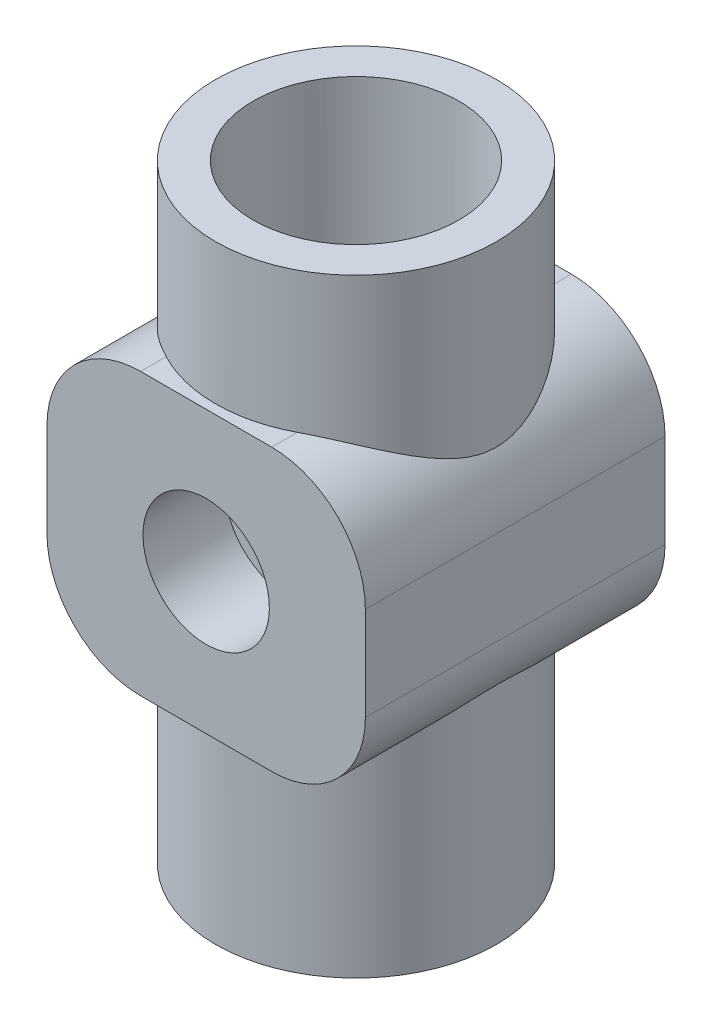
from build123d import *

# Parameters (mm, degrees)
BOSS_EXTRUDE1_DEPTH      = 16
SKETCH2_R                = 15
SKETCH2_R_2              = 11
BOSS_EXTRUDE2_DEPTH      = 30
BOSS_EXTRUDE2_DEPTH_BACK = 35
SKETCH3_R                = 6.75
CUT_EXTRUDE1_DEPTH       = 8.75
SKETCH4_R                = 11
CUT_EXTRUDE2_DEPTH       = 24


with BuildPart() as part:
    # Sketch1 → Boss-Extrude1 (new body, symmetric)
    with BuildSketch(Plane.XY):
        with BuildLine():
            Line((-7, -15), (7, -15))
            ThreePointArc((7, -15), (14.071067812, -12.071067812), (17, -5))
            Line((17, -5), (17, 5))
            ThreePointArc((17, 5), (14.071067812, 12.071067812), (7, 15))
            Line((7, 15), (-7, 15))
            ThreePointArc((-7, 15), (-14.071067812, 12.071067812), (-17, 5))
            Line((-17, 5), (-17, -5))
            ThreePointArc((-17, -5), (-14.071067812, -12.071067812), (-7, -15))
        make_face()
    extrude(amount=BOSS_EXTRUDE1_DEPTH, both=True)

    # Sketch2 → Boss-Extrude2 (add, two sides)
    with BuildSketch(Plane(origin=(0, 0, 0), x_dir=(1, 0, 0), z_dir=(0, 1, 0))) as boss_extrude2_sk:
        Circle(SKETCH2_R)
        Circle(SKETCH2_R_2, mode=Mode.SUBTRACT)
    extrude(amount=BOSS_EXTRUDE2_DEPTH)
    extrude(boss_extrude2_sk.sketch, amount=-BOSS_EXTRUDE2_DEPTH_BACK)

    # Sketch3 → Cut-Extrude1 (cut)
    with BuildSketch(Plane(origin=(0, 0, -16), x_dir=(-1, 0, 0), z_dir=(0, 0, -1))):
        Circle(SKETCH3_R)
    cut_extrude1 = extrude(amount=-CUT_EXTRUDE1_DEPTH, mode=Mode.SUBTRACT)

    # Mirror1: Cut-Extrude1 across plane
    add(cut_extrude1.mirror(Plane.XY), mode=Mode.SUBTRACT)

    # Sketch4 → Cut-Extrude2 (cut)
    with BuildSketch(Plane(origin=(0, 30, 0), x_dir=(1, 0, 0), z_dir=(0, 1, 0))):
        Circle(SKETCH4_R)
    extrude(amount=-CUT_EXTRUDE2_DEPTH, mode=Mode.SUBTRACT)


solid = part.part
